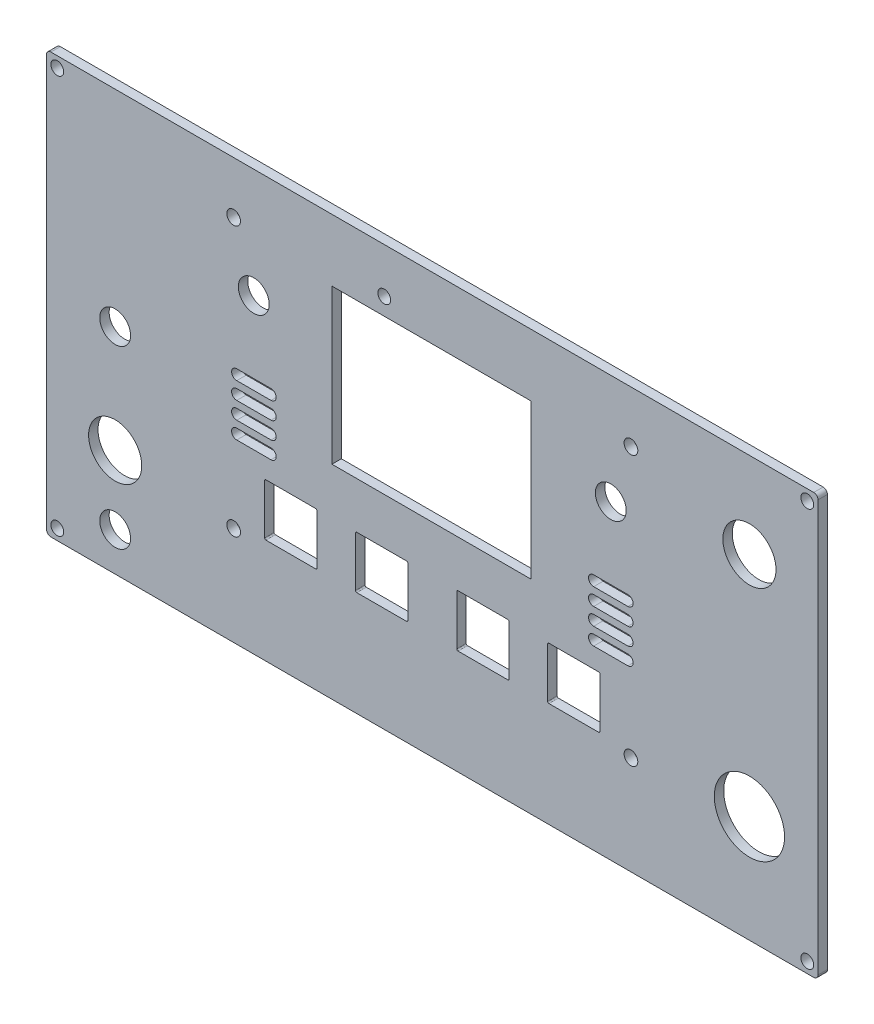
from build123d import *

# Parameters (mm, degrees)
SKETCH_1_W      = 180
SKETCH_1_H      = 98
SKETCH_1_R      = 6.2
SKETCH_1_R_2    = 8.2
SKETCH_1_R_3    = 1.5
SKETCH_1_R_4    = 1.6
SKETCH_1_R_5    = 3.6
SKETCH_1_W_2    = 12.2
SKETCH_1_H_2    = 12.2
SKETCH_1_W_3    = 46.5
SKETCH_1_H_3    = 36
EXTRUDE_1_DEPTH = 2.2
FILLET_1_R      = 1
FILLET_2_R      = 0.3


with BuildPart() as part:
    # Эскиз1 → Бобышка-Вытянуть1 (new body)
    with BuildSketch(Plane.XY):
        with Locations((49.911, 29.5)):
            Rectangle(SKETCH_1_W, SKETCH_1_H)
        with Locations((-24.089, 5.5)):
            Circle(SKETCH_1_R, mode=Mode.SUBTRACT)
        with Locations((123.911, 58.5)):
            Circle(SKETCH_1_R, mode=Mode.SUBTRACT)
        with Locations((123.911, 5.5)):
            Circle(SKETCH_1_R_2, mode=Mode.SUBTRACT)
        with Locations((-37.589, 76)):
            Circle(SKETCH_1_R_3, mode=Mode.SUBTRACT)
        with Locations((137.411, 76)):
            Circle(SKETCH_1_R_3, mode=Mode.SUBTRACT)
        with Locations((137.411, -17)):
            Circle(SKETCH_1_R_3, mode=Mode.SUBTRACT)
        with Locations((-37.589, -17)):
            Circle(SKETCH_1_R_3, mode=Mode.SUBTRACT)
        with Locations((3.556, 3.556)):
            Circle(SKETCH_1_R_4, mode=Mode.SUBTRACT)
        with Locations((3.556, 66.421)):
            Circle(SKETCH_1_R_4, mode=Mode.SUBTRACT)
        with Locations((96.266, 66.421)):
            Circle(SKETCH_1_R_4, mode=Mode.SUBTRACT)
        with Locations((96.266, 3.556)):
            Circle(SKETCH_1_R_4, mode=Mode.SUBTRACT)
        with Locations((8.255, 52.959)):
            Circle(SKETCH_1_R_5, mode=Mode.SUBTRACT)
        with Locations((91.567, 52.959)):
            Circle(SKETCH_1_R_5, mode=Mode.SUBTRACT)
        with Locations((-24.089, 30.5)):
            Circle(SKETCH_1_R_5, mode=Mode.SUBTRACT)
        with Locations((-24.089, -10.5)):
            Circle(SKETCH_1_R_5, mode=Mode.SUBTRACT)
        with Locations((38.7, 68)):
            Circle(SKETCH_1_R_3, mode=Mode.SUBTRACT)
        with Locations((16.891, 11.049)):
            Rectangle(SKETCH_1_W_2, SKETCH_1_H_2, mode=Mode.SUBTRACT)
        with Locations((38.1, 11.049)):
            Rectangle(SKETCH_1_W_2, SKETCH_1_H_2, mode=Mode.SUBTRACT)
        with Locations((61.722, 11.049)):
            Rectangle(SKETCH_1_W_2, SKETCH_1_H_2, mode=Mode.SUBTRACT)
        with Locations((82.931, 11.049)):
            Rectangle(SKETCH_1_W_2, SKETCH_1_H_2, mode=Mode.SUBTRACT)
        with Locations((49.75, 46)):
            Rectangle(SKETCH_1_W_3, SKETCH_1_H_3, mode=Mode.SUBTRACT)
        with BuildLine():
            Line((4.282953003, 36.1885), (12.282953003, 36.1885))
            ThreePointArc((12.282953003, 36.1885), (13.482953003, 34.9885), (12.282953003, 33.7885))
            Line((12.282953003, 33.7885), (4.282953003, 33.7885))
            ThreePointArc((4.282953003, 33.7885), (3.082953003, 34.9885), (4.282953003, 36.1885))
        make_face(mode=Mode.SUBTRACT)
        with BuildLine():
            Line((95.567, 33.7885), (87.567, 33.7885))
            ThreePointArc((87.567, 33.7885), (86.367, 34.9885), (87.567, 36.1885))
            Line((87.567, 36.1885), (95.567, 36.1885))
            ThreePointArc((95.567, 36.1885), (96.767, 34.9885), (95.567, 33.7885))
        make_face(mode=Mode.SUBTRACT)
        with BuildLine():
            Line((4.282953003, 32.1885), (12.282953003, 32.1885))
            ThreePointArc((12.282953003, 32.1885), (13.482953003, 30.9885), (12.282953003, 29.7885))
            Line((12.282953003, 29.7885), (4.282953003, 29.7885))
            ThreePointArc((4.282953003, 29.7885), (3.082953003, 30.9885), (4.282953003, 32.1885))
        make_face(mode=Mode.SUBTRACT)
        with BuildLine():
            Line((95.567, 29.7885), (87.567, 29.7885))
            ThreePointArc((87.567, 29.7885), (86.367, 30.9885), (87.567, 32.1885))
            Line((87.567, 32.1885), (95.567, 32.1885))
            ThreePointArc((95.567, 32.1885), (96.767, 30.9885), (95.567, 29.7885))
        make_face(mode=Mode.SUBTRACT)
        with BuildLine():
            Line((4.282953003, 28.1885), (12.282953003, 28.1885))
            ThreePointArc((12.282953003, 28.1885), (13.482953003, 26.9885), (12.282953003, 25.7885))
            Line((12.282953003, 25.7885), (4.282953003, 25.7885))
            ThreePointArc((4.282953003, 25.7885), (3.082953003, 26.9885), (4.282953003, 28.1885))
        make_face(mode=Mode.SUBTRACT)
        with BuildLine():
            Line((95.567, 25.7885), (87.567, 25.7885))
            ThreePointArc((87.567, 25.7885), (86.367, 26.9885), (87.567, 28.1885))
            Line((87.567, 28.1885), (95.567, 28.1885))
            ThreePointArc((95.567, 28.1885), (96.767, 26.9885), (95.567, 25.7885))
        make_face(mode=Mode.SUBTRACT)
        with BuildLine():
            Line((4.282953003, 24.1885), (12.282953003, 24.1885))
            ThreePointArc((12.282953003, 24.1885), (13.482953003, 22.9885), (12.282953003, 21.7885))
            Line((12.282953003, 21.7885), (4.282953003, 21.7885))
            ThreePointArc((4.282953003, 21.7885), (3.082953003, 22.9885), (4.282953003, 24.1885))
        make_face(mode=Mode.SUBTRACT)
        with BuildLine():
            Line((95.567, 21.7885), (87.567, 21.7885))
            ThreePointArc((87.567, 21.7885), (86.367, 22.9885), (87.567, 24.1885))
            Line((87.567, 24.1885), (95.567, 24.1885))
            ThreePointArc((95.567, 24.1885), (96.767, 22.9885), (95.567, 21.7885))
        make_face(mode=Mode.SUBTRACT)
    extrude(amount=EXTRUDE_1_DEPTH)

    # Скругление1
    fillet_1_edges = [part.edges().sort_by_distance(p)[0] for p in [
        (139.911, -19.5, 1.1),
        (-40.089, -19.5, 1.1),
        (-40.089, 78.5, 1.1),
        (139.911, 78.5, 1.1),
    ]]
    fillet(fillet_1_edges, radius=FILLET_1_R)

    # Скругление2
    fillet_2_edges = [part.edges().sort_by_distance(p)[0] for p in [
        (89.031, 4.949, 1.1),
        (89.031, 17.149, 1.1),
        (76.831, 17.149, 1.1),
        (76.831, 4.949, 1.1),
        (22.991, 4.949, 1.1),
        (22.991, 17.149, 1.1),
        (10.791, 17.149, 1.1),
        (10.791, 4.949, 1.1),
        (44.2, 4.949, 1.1),
        (44.2, 17.149, 1.1),
        (32, 17.149, 1.1),
        (32, 4.949, 1.1),
        (67.822, 4.949, 1.1),
        (67.822, 17.149, 1.1),
        (55.622, 17.149, 1.1),
        (55.622, 4.949, 1.1),
    ]]
    fillet(fillet_2_edges, radius=FILLET_2_R)


solid = part.part
